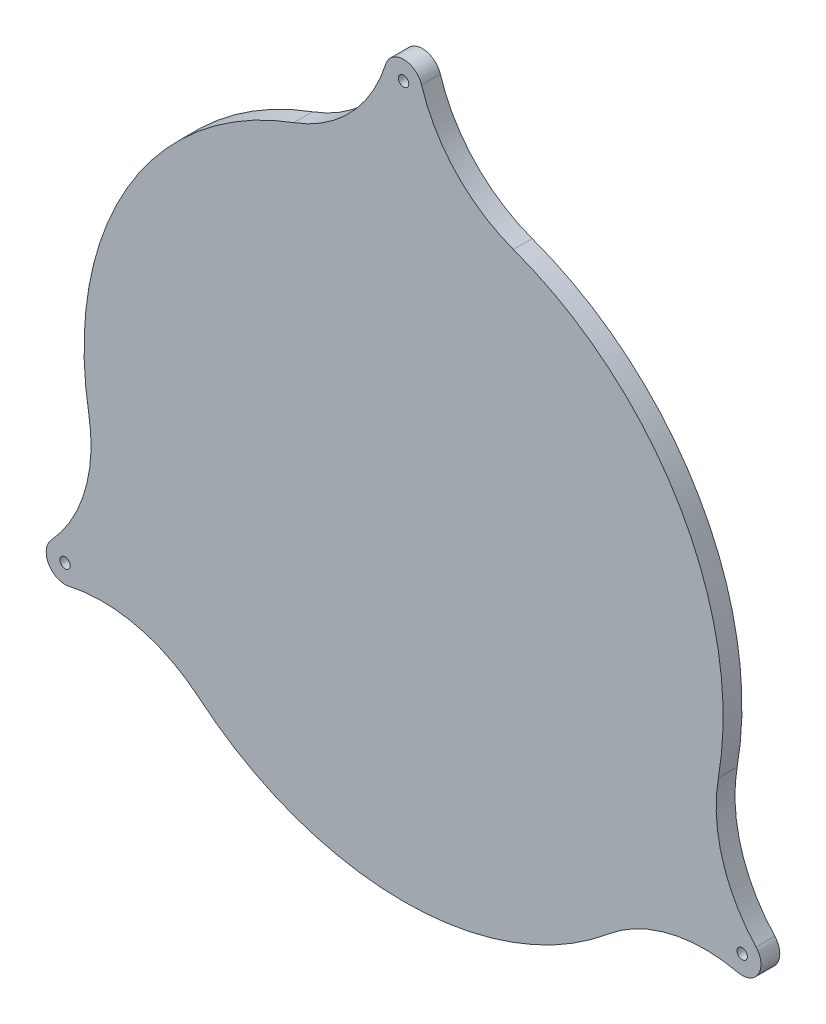
from build123d import *

# Parameters (mm, degrees)
SKETCH1_R           = 1.375
BOSS_EXTRUDE1_DEPTH = 5


with BuildPart() as part:
    # Sketch1 → Boss-Extrude1 (new body)
    with BuildSketch(Plane.XY):
        with BuildLine():
            ThreePointArc((-29.215098796, 79.821538462), (-73.612159322, 42.5), (-83.735029475, -14.6097515))
            ThreePointArc((-83.735029475, -14.6097515), (-84.767114048, -32.77832805), (-93.741431686, -48.60943652))
            ThreePointArc((-93.741431686, -48.60943652), (-94.396769013, -54.5), (-88.967722733, -56.877742968))
            ThreePointArc((-88.967722733, -56.877742968), (-70.770421809, -57.021310146), (-54.519930679, -65.211786962))
            ThreePointArc((-54.519930679, -65.211786962), (0, -85), (54.519930679, -65.211786962))
            ThreePointArc((54.519930679, -65.211786962), (70.770421809, -57.021310146), (88.967722733, -56.877742968))
            ThreePointArc((88.967722733, -56.877742968), (94.396769013, -54.5), (93.741431686, -48.60943652))
            ThreePointArc((93.741431686, -48.60943652), (84.767114048, -32.77832805), (83.735029475, -14.6097515))
            ThreePointArc((83.735029475, -14.6097515), (73.612159322, 42.5), (29.215098796, 79.821538462))
            ThreePointArc((29.215098796, 79.821538462), (13.996692239, 89.799638196), (4.773708954, 105.487179487))
            ThreePointArc((4.773708954, 105.487179487), (0, 109), (-4.773708954, 105.487179487))
            ThreePointArc((-4.773708954, 105.487179487), (-13.996692239, 89.799638196), (-29.215098796, 79.821538462))
        make_face()
        with Locations((0, 104)):
            Circle(SKETCH1_R, mode=Mode.SUBTRACT)
        with Locations((90.066641994, -52)):
            Circle(SKETCH1_R, mode=Mode.SUBTRACT)
        with Locations((-90.066641994, -52)):
            Circle(SKETCH1_R, mode=Mode.SUBTRACT)
    extrude(amount=BOSS_EXTRUDE1_DEPTH)


solid = part.part
